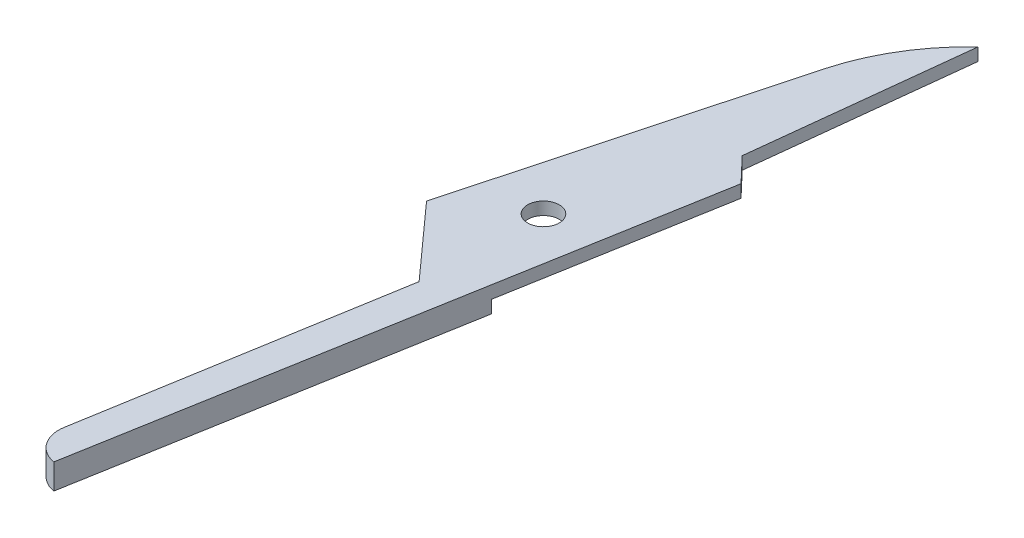
from build123d import *

# Parameters (mm, degrees)
BOSS_EXTRUDE1_DEPTH = 1.6
SKETCH2_R           = 1
CUT_EXTRUDE1_DEPTH  = 2.6
CUT_EXTRUDE2_DEPTH  = 0.8


with BuildPart() as part:
    # Sketch1 → Boss-Extrude1 (new body)
    with BuildSketch(Plane(origin=(0, 0, 0), x_dir=(1, 0, 0), z_dir=(0, 1, 0))):
        with BuildLine():
            Line((-9, 26.094133447), (-3.675272118, 45.890528901))
            ThreePointArc((-3.675272118, 45.890528901), (-2.266272493, 49.203119101), (0, 52))
            Line((0, 52), (-1.5, 38.573765251))
            Line((-1.5, 38.573765251), (0, 37))
            Line((0, 37), (-6.5, 0))
            ThreePointArc((-6.5, 0), (-7.739867281, 0.785826002), (-8.065788204, 2.217108271))
            Line((-8.065788204, 2.217108271), (-4.822378182, 21.445480314))
            Line((-4.822378182, 21.445480314), (-9, 26.094133447))
        make_face()
    extrude(amount=BOSS_EXTRUDE1_DEPTH)

    # Sketch2 → Cut-Extrude1 (cut, through all)
    with BuildSketch(Plane(origin=(0, 1.6, 0), x_dir=(1, 0, 0), z_dir=(0, 1, 0))):
        with Locations((-4.6, 29.094133447)):
            Circle(SKETCH2_R)
    extrude(amount=-CUT_EXTRUDE1_DEPTH, mode=Mode.SUBTRACT)

    # Sketch4 → Cut-Extrude2 (cut)
    with BuildSketch(Plane.XZ):
        Polygon((-5.441038935, -22.133895727), (-15.455204314, -22.133895727), (-15.455204314, -68.130413952), (6.621463741, -68.130413952), (6.621463741, -27.758733102), align=None)
    extrude(amount=-CUT_EXTRUDE2_DEPTH, mode=Mode.SUBTRACT)


solid = part.part
